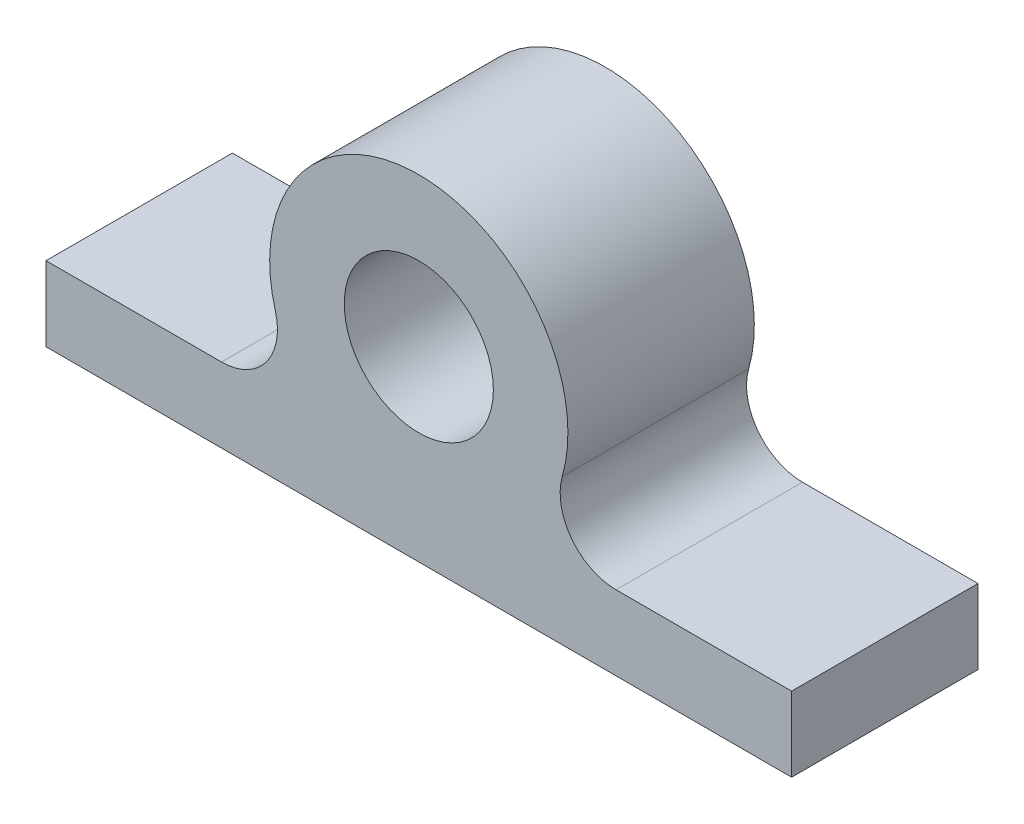
from build123d import *

# Parameters (mm, degrees)
SKETCH1_R                = 8
SKETCH1_R_2              = 4
BOSS_EXTRUDE1_DEPTH      = 10
BOSS_EXTRUDE3_DEPTH      = 2
BOSS_EXTRUDE3_DEPTH_BACK = 2
SKETCH2_W                = 40
SKETCH2_H                = 10
FILLET1_R                = 3


with BuildPart() as part:
    # Sketch1 → Boss-Extrude1 (new body)
    with BuildSketch(Plane.XY):
        Circle(SKETCH1_R)
        Circle(SKETCH1_R_2, mode=Mode.SUBTRACT)
    extrude(amount=-BOSS_EXTRUDE1_DEPTH)

    # Sketch2 → Boss-Extrude3 (add, two sides: drawn at the far end of the back side and taken through both)
    with BuildSketch(Plane(origin=(0, -8, 0), x_dir=(-1, 0, 0), z_dir=(0, -1, 0)).offset(-BOSS_EXTRUDE3_DEPTH_BACK)):
        with Locations((0, 5)):
            Rectangle(SKETCH2_W, SKETCH2_H)
    extrude(amount=BOSS_EXTRUDE3_DEPTH + BOSS_EXTRUDE3_DEPTH_BACK)

    # Fillet1
    fillet1_edges = [part.edges().sort_by_distance(p)[0] for p in [
        (5.291502622, -6, -5),
        (-5.291502622, -6, -5),
    ]]
    fillet(fillet1_edges, radius=FILLET1_R)


solid = part.part
